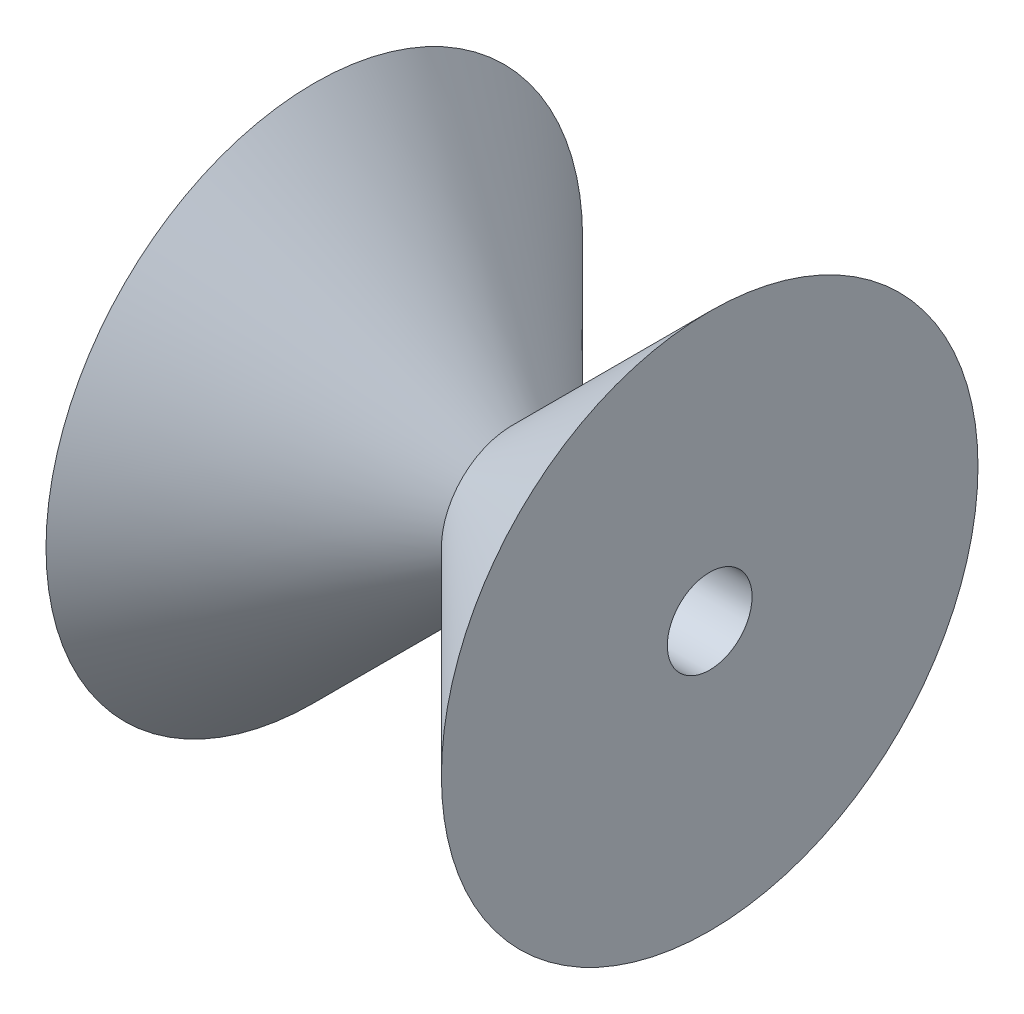
from build123d import *

# Parameters (mm, degrees)
SKETCH1_R              = 12.5
BOSS_EXTRUDE1_DEPTH    = 35
BOSS_EXTRUDE1_TAPER    = -45
SKETCH2_R              = 7.5
SUPPORT_ARM_HOLE_DEPTH = 71.0000001


with BuildPart() as part:
    # Sketch1 → Boss-Extrude1 (new body)
    with BuildSketch(Plane(origin=(0, 0, 0), x_dir=(0, 0, -1), z_dir=(1, 0, 0))):
        Circle(SKETCH1_R)
    boss_extrude1 = extrude(amount=BOSS_EXTRUDE1_DEPTH, taper=BOSS_EXTRUDE1_TAPER)

    # Mirror1: Boss-Extrude1 across plane
    add(boss_extrude1.mirror(Plane(origin=(0, 0, 0), x_dir=(0, 0, 1), z_dir=(1, 0, 0))))

    # Sketch2 → Support Arm Hole (cut, through all)
    with BuildSketch(Plane(origin=(35, 0, 0), x_dir=(0, 0, -1), z_dir=(1, 0, 0))):
        Circle(SKETCH2_R)
    extrude(amount=-SUPPORT_ARM_HOLE_DEPTH, mode=Mode.SUBTRACT)


solid = part.part
